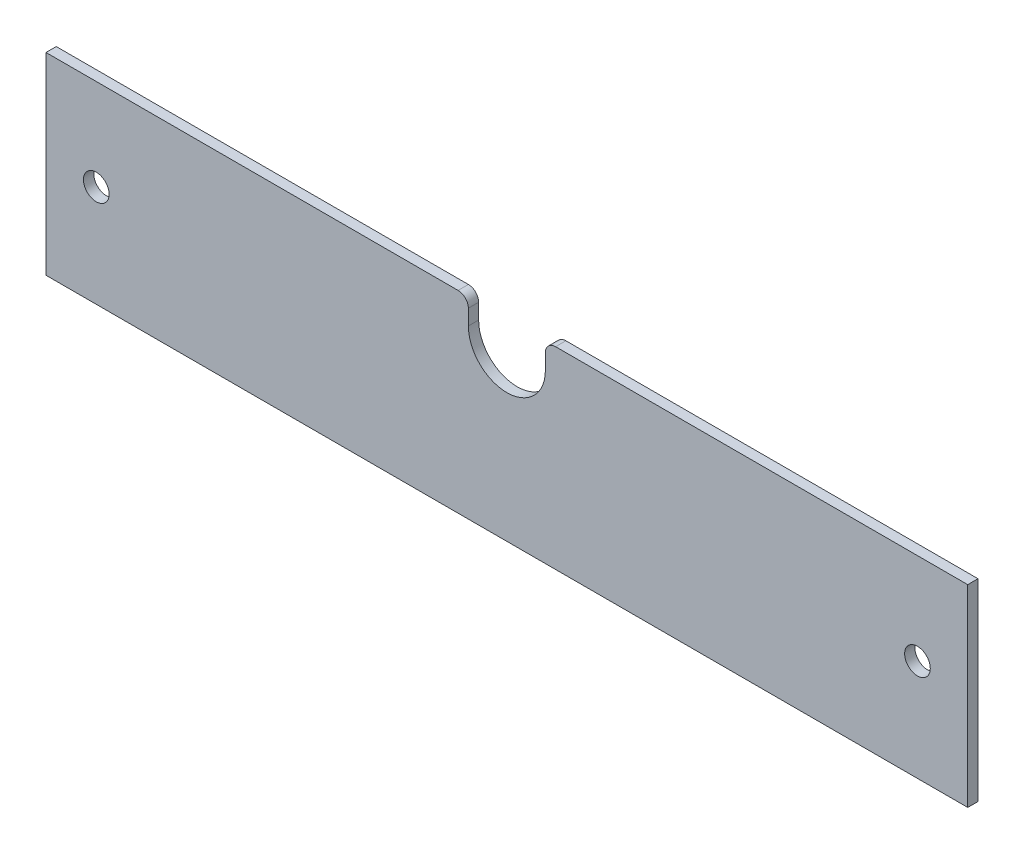
from build123d import *

# Parameters (mm, degrees)
ESQUISSE1_R        = 2.5
BOSS_EXTRU_1_DEPTH = 2
CONG_1_R           = 2


with BuildPart() as part:
    # Esquisse1 → Boss.-Extru.1 (new body)
    with BuildSketch(Plane.XY):
        with BuildLine():
            Line((-89.8, 18.8), (-89.8, -18.8))
            Line((-89.8, -18.8), (89.8, -18.8))
            Line((89.8, -18.8), (89.8, 18.8))
            Line((89.8, 18.8), (7.5, 18.8))
            Line((7.5, 18.8), (7.5, 13.8))
            ThreePointArc((7.5, 13.8), (0, 6.3), (-7.5, 13.8))
            Line((-7.5, 13.8), (-7.5, 18.8))
            Line((-7.5, 18.8), (-89.8, 18.8))
        make_face()
        with Locations((-80, 1)):
            Circle(ESQUISSE1_R, mode=Mode.SUBTRACT)
        with Locations((80, 1)):
            Circle(ESQUISSE1_R, mode=Mode.SUBTRACT)
    extrude(amount=BOSS_EXTRU_1_DEPTH)

    # Congé1
    cong_1_edges = [part.edges().sort_by_distance(p)[0] for p in [
        (7.5, 18.8, 1),
        (-7.5, 18.8, 1),
    ]]
    fillet(cong_1_edges, radius=CONG_1_R)


solid = part.part
